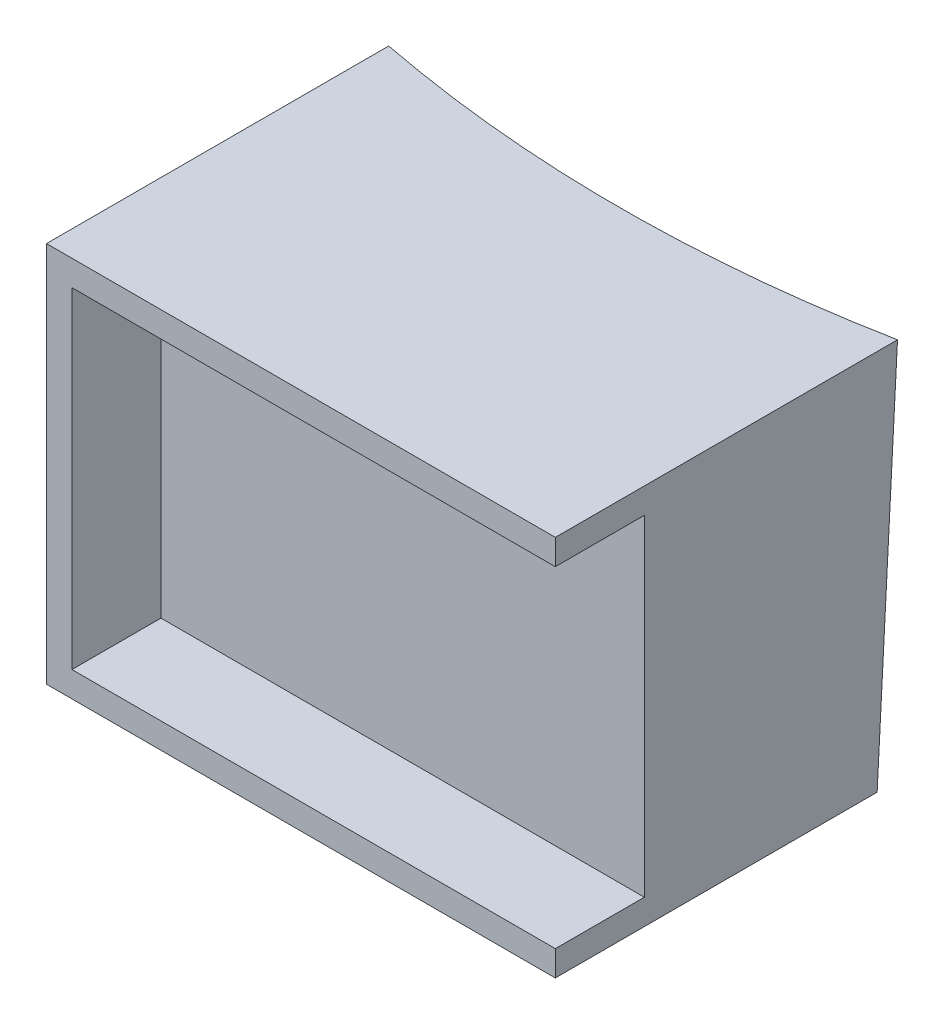
from build123d import *

# Parameters (mm, degrees)
SKETCH1_W           = 40
SKETCH1_H           = 30
BOSS_EXTRUDE1_DEPTH = 130
SKETCH6_W           = 30
SKETCH6_H           = 20
CUT_EXTRUDE1_DEPTH  = 10
SKETCH7_W           = 38
SKETCH7_H           = 26
CUT_EXTRUDE2_DEPTH  = 7


with BuildPart() as part:
    # Sketch1 → Boss-Extrude1 (new body)
    with BuildSketch(Plane.XY):
        with Locations((20, 15)):
            Rectangle(SKETCH1_W, SKETCH1_H)
    extrude(amount=BOSS_EXTRUDE1_DEPTH)

    # Sketch4 → Cut-Revolve1 (revolve, cut)
    with BuildSketch(Plane(origin=(20, 0, 0), x_dir=(0, 0, -1), z_dir=(1, 0, 0))):
        Polygon((0, 60), (0, -170), (-115.503789235, -170), (-103.45, 60), align=None)
    revolve(axis=Axis((20, 60, 0), (0, -1, 0)), mode=Mode.SUBTRACT)

    # Sketch6 → Cut-Extrude1 (cut)
    with BuildSketch(Plane.XY.offset(120)):
        with Locations((20, 15)):
            Rectangle(SKETCH6_W, SKETCH6_H)
    extrude(amount=-CUT_EXTRUDE1_DEPTH, mode=Mode.SUBTRACT)

    # Sketch7 → Cut-Extrude2 (cut)
    with BuildSketch(Plane.XY.offset(130)):
        with Locations((21, 15)):
            Rectangle(SKETCH7_W, SKETCH7_H)
    extrude(amount=-CUT_EXTRUDE2_DEPTH, mode=Mode.SUBTRACT)


solid = part.part
